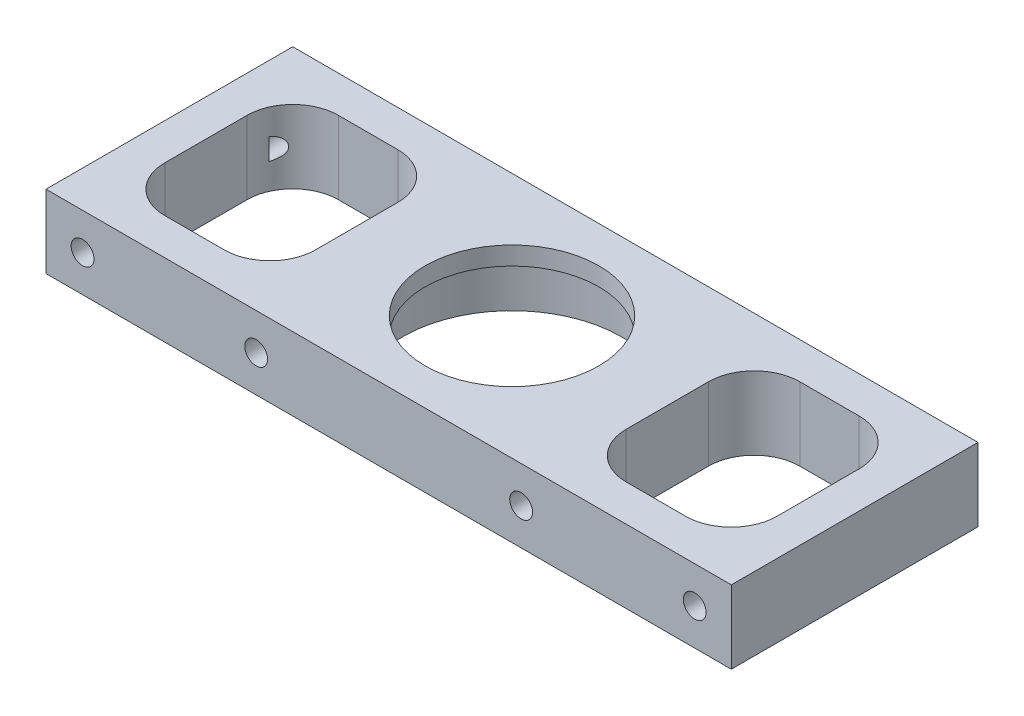
from build123d import *

# Parameters (mm, degrees)
SKETCH_1_W           = 75
SKETCH_1_H           = 27
SKETCH_1_R           = 9.5
EXTRUDE_1_DEPTH      = 8
SKETCH_9_R           = 12
CUT_EXTRUDE_7_DEPTH  = 6
SKETCH_11_R          = 1.25
CUT_EXTRUDE_8_DEPTH  = 7
SKETCH_12_R          = 1.25
CUT_EXTRUDE_9_DEPTH  = 7
SKETCH_13_R          = 1.25
CUT_EXTRUDE_10_DEPTH = 6


with BuildPart() as part:
    # Эскиз1 → Бобышка-Вытянуть1 (new body)
    with BuildSketch(Plane(origin=(0, 0, 0), x_dir=(1, 0, 0), z_dir=(0, 1, 0))):
        Rectangle(SKETCH_1_W, SKETCH_1_H)
        with Locations(Location((0, 0, 0), (0, 0, 270))):  # turned: the seam where the file's is
            Circle(SKETCH_1_R, mode=Mode.SUBTRACT)
        with BuildLine():
            Line((-28.5, 9.5), (-22, 9.5))
            ThreePointArc((-22, 9.5), (-18.464466094, 8.035533906), (-17, 4.5))
            Line((-17, 4.5), (-17, -4.5))
            ThreePointArc((-17, -4.5), (-18.464466094, -8.035533906), (-22, -9.5))
            Line((-22, -9.5), (-28.5, -9.5))
            ThreePointArc((-28.5, -9.5), (-32.035533906, -8.035533906), (-33.5, -4.5))
            Line((-33.5, -4.5), (-33.5, 4.5))
            ThreePointArc((-33.5, 4.5), (-32.035533906, 8.035533906), (-28.5, 9.5))
        make_face(mode=Mode.SUBTRACT)
        with BuildLine():
            Line((28.5, 9.5), (22, 9.5))
            ThreePointArc((22, 9.5), (18.464466094, 8.035533906), (17, 4.5))
            Line((17, 4.5), (17, -4.5))
            ThreePointArc((17, -4.5), (18.464466094, -8.035533906), (22, -9.5))
            Line((22, -9.5), (28.5, -9.5))
            ThreePointArc((28.5, -9.5), (32.035533906, -8.035533906), (33.5, -4.5))
            Line((33.5, -4.5), (33.5, 4.5))
            ThreePointArc((33.5, 4.5), (32.035533906, 8.035533906), (28.5, 9.5))
        make_face(mode=Mode.SUBTRACT)
    extrude(amount=EXTRUDE_1_DEPTH)

    # Эскиз9 → Вырез-Вытянуть7 (cut)
    with BuildSketch(Plane.XZ):
        with Locations(Location((0, 0, 0), (0, 0, 270))):  # turned: the seam where the file's is
            Circle(SKETCH_9_R)
    extrude(amount=-CUT_EXTRUDE_7_DEPTH, mode=Mode.SUBTRACT)

    # Эскиз11 → Вырез-Вытянуть8 (cut)
    with BuildSketch(Plane(origin=(0, 0, -13.5), x_dir=(-1, 0, 0), z_dir=(0, 0, -1))):
        with Locations((14.5, 4)):
            Circle(SKETCH_11_R)
        with Locations((33.5, 4)):
            Circle(SKETCH_11_R)
        with Locations(Location((-33.5, 4, 0), (0, 0, 70.49194101))):  # turned: the seam where the file's is
            Circle(SKETCH_11_R)
        with Locations(Location((-14.5, 4, 0), (0, 0, 180))):  # turned: the seam where the file's is
            Circle(SKETCH_11_R)
    extrude(amount=-CUT_EXTRUDE_8_DEPTH, mode=Mode.SUBTRACT)

    # Эскиз12 → Вырез-Вытянуть9 (cut)
    with BuildSketch(Plane.XY.offset(13.5)):
        with Locations(Location((-14.5, 4, 0), (0, 0, 180))):  # turned: the seam where the file's is
            Circle(SKETCH_12_R)
        with Locations(Location((-33.5, 4, 0), (0, 0, 180))):  # turned: the seam where the file's is
            Circle(SKETCH_12_R)
        with Locations((14.5, 4)):
            Circle(SKETCH_12_R)
        with Locations(Location((33.5, 4, 0), (0, 0, 109.50805899))):  # turned: the seam where the file's is
            Circle(SKETCH_12_R)
    extrude(amount=-CUT_EXTRUDE_9_DEPTH, mode=Mode.SUBTRACT)

    # Эскиз13 → Вырез-Вытянуть10 (cut)
    with BuildSketch(Plane.XZ):
        with Locations(Location((-11.29380733, 9.083435331, 0), (0, 0, 270))):  # turned: the seam where the file's is
            Circle(SKETCH_13_R)
        with Locations(Location((11.29380733, 9.083435331, 0), (0, 0, 90))):  # turned: the seam where the file's is
            Circle(SKETCH_13_R)
        with Locations(Location((11.29380733, -9.083435331, 0), (0, 0, 270))):  # turned: the seam where the file's is
            Circle(SKETCH_13_R)
        with Locations(Location((-11.29380733, -9.083435331, 0), (0, 0, 90))):  # turned: the seam where the file's is
            Circle(SKETCH_13_R)
    extrude(amount=-CUT_EXTRUDE_10_DEPTH, mode=Mode.SUBTRACT)


solid = part.part
